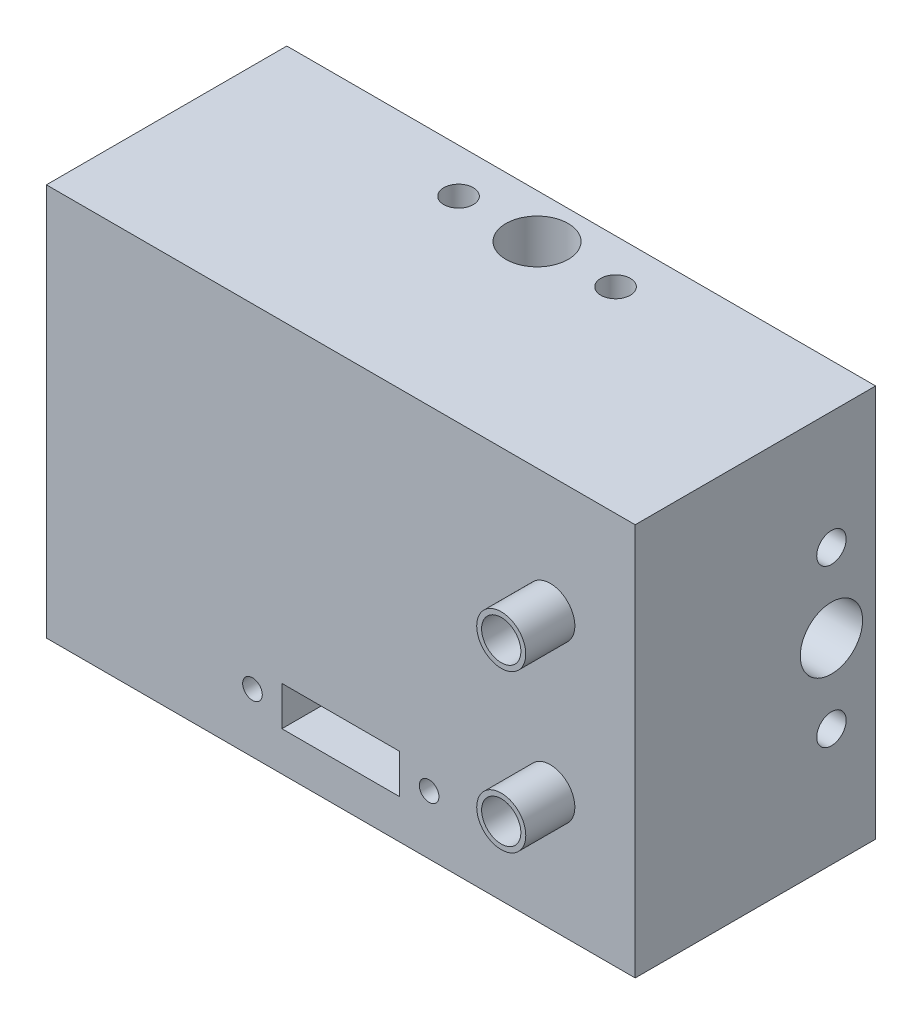
from build123d import *

# Parameters (mm, degrees)
SKETCH1_W           = 60
SKETCH1_H           = 40
BOSS_EXTRUDE1_DEPTH = 24.5
SKETCH2_R           = 15
SKETCH2_R_2         = 14
BOSS_EXTRUDE2_DEPTH = 1
SKETCH3_R           = 3.175
SKETCH3_R_2         = 1.5
CUT_EXTRUDE1_DEPTH  = 10
SKETCH4_R           = 3.175
SKETCH4_R_2         = 1.5
CUT_EXTRUDE2_DEPTH  = 10
SKETCH5_R           = 1
SKETCH5_W           = 12
SKETCH5_H           = 4
CUT_EXTRUDE3_DEPTH  = 5
SKETCH6_R           = 2.5
SKETCH6_R_2         = 2
BOSS_EXTRUDE4_DEPTH = 5


with BuildPart() as part:
    # Sketch1 → Boss-Extrude1 (new body)
    with BuildSketch(Plane.XY):
        with Locations((30, 20)):
            Rectangle(SKETCH1_W, SKETCH1_H)
    extrude(amount=BOSS_EXTRUDE1_DEPTH)

    # Sketch2 → Boss-Extrude2 (add)
    with BuildSketch(Plane(origin=(0, 0, 0), x_dir=(-1, 0, 0), z_dir=(0, 0, -1))):
        with Locations((-30, 20)):
            Circle(SKETCH2_R)
        with Locations((-30, 20)):
            Circle(SKETCH2_R_2, mode=Mode.SUBTRACT)
    extrude(amount=BOSS_EXTRUDE2_DEPTH)

    # Sketch3 → Cut-Extrude1 (cut)
    with BuildSketch(Plane.ZY):
        with Locations((4.5, 20)):
            Circle(SKETCH3_R)
        with Locations((4.5, 28)):
            Circle(SKETCH3_R_2)
        with Locations((4.5, 12)):
            Circle(SKETCH3_R_2)
    cut_extrude1 = extrude(amount=-CUT_EXTRUDE1_DEPTH, mode=Mode.SUBTRACT)

    # Mirror1: Cut-Extrude1 across plane
    add(cut_extrude1.mirror(Plane(origin=(30, 0, 0), x_dir=(0, 0, 1), z_dir=(1, 0, 0))), mode=Mode.SUBTRACT)

    # Sketch4 → Cut-Extrude2 (cut)
    with BuildSketch(Plane(origin=(0, 40, 0), x_dir=(1, 0, 0), z_dir=(0, 1, 0))):
        with Locations((30, -4.5)):
            Circle(SKETCH4_R)
        with Locations((38, -4.5)):
            Circle(SKETCH4_R_2)
        with Locations((22, -4.5)):
            Circle(SKETCH4_R_2)
    cut_extrude2 = extrude(amount=-CUT_EXTRUDE2_DEPTH, mode=Mode.SUBTRACT)

    # Mirror2: Cut-Extrude2 across plane
    add(cut_extrude2.mirror(Plane(origin=(0, 20, 0), x_dir=(0, 0, 1), z_dir=(0, -1, 0))), mode=Mode.SUBTRACT)

    # Sketch5 → Cut-Extrude3 (cut)
    with BuildSketch(Plane.XY.offset(24.5)):
        with Locations((21, 6)):
            Circle(SKETCH5_R)
        with Locations((39, 6)):
            Circle(SKETCH5_R)
        with Locations((30, 6)):
            Rectangle(SKETCH5_W, SKETCH5_H)
    extrude(amount=-CUT_EXTRUDE3_DEPTH, mode=Mode.SUBTRACT)

    # Sketch6 → Boss-Extrude4 (add)
    with BuildSketch(Plane.XY.offset(24.5)):
        with Locations((51.35, 12)):
            Circle(SKETCH6_R)
        with Locations((51.35, 12)):
            Circle(SKETCH6_R_2, mode=Mode.SUBTRACT)
        with Locations((51.35, 28)):
            Circle(SKETCH6_R)
        with Locations((51.35, 28)):
            Circle(SKETCH6_R_2, mode=Mode.SUBTRACT)
    extrude(amount=BOSS_EXTRUDE4_DEPTH)


solid = part.part
